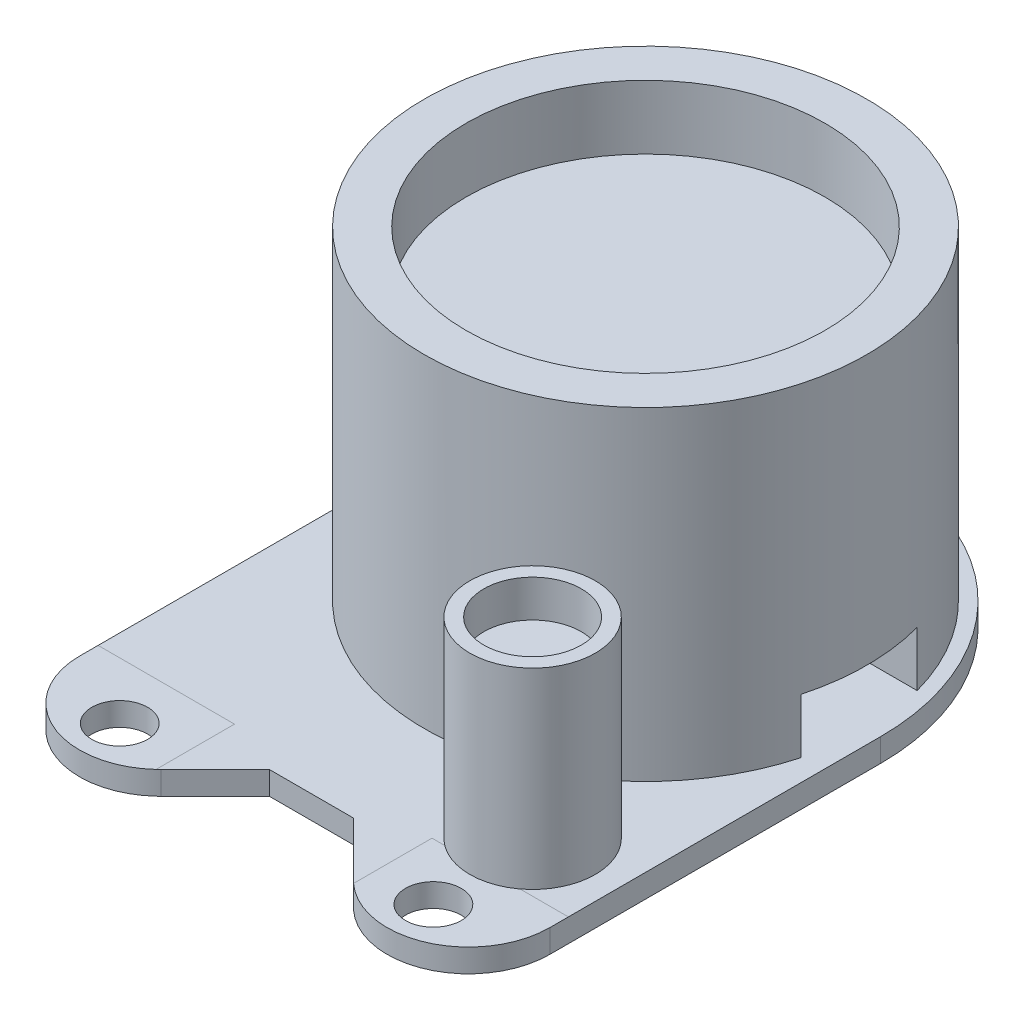
from build123d import *

# Parameters (mm, degrees)
SKETCH1_R               = 1.2
BOSS_EXTRUDE1_DEPTH     = 1
SKETCH4_R               = 9.525
SKETCH4_R_2             = 7.725
BOSS_EXTRUDE2_DEPTH     = 13.94
SKETCH5_W               = 5
SKETCH5_H               = 2.36
CUT_EXTRUDE1_DEPTH      = 11.12
CUT_EXTRUDE1_DEPTH_BACK = 11.12
BOSS_EXTRUDE3_START     = -2.75
SKETCH6_R               = 7.725
BOSS_EXTRUDE3_DEPTH     = 8.83
SKETCH7_R               = 2.7
SKETCH7_R_2             = 2.1
EXTRUDE_THIN1_DEPTH     = 8.25
BOSS_EXTRUDE4_START     = -1.6
SKETCH8_R               = 2.1
BOSS_EXTRUDE4_DEPTH     = 6.65
SKETCH9_R               = 4
CUT_EXTRUDE2_DEPTH      = 6.45
FILLET1_R               = 4
BOSS_EXTRUDE5_DEPTH     = 2.36


with BuildPart() as part:
    # Sketch1 → Boss-Extrude1 (new body)
    with BuildSketch(Plane(origin=(0, 0, 0), x_dir=(1, 0, 0), z_dir=(0, 1, 0))):
        with BuildLine():
            Line((-10.12, 0), (-10.12, -14.24))
            ThreePointArc((-10.12, -14.24), (-7.959392013, -17.473578364), (-4.145126266, -16.714873734))
            Line((-4.145126266, -16.714873734), (-1.810252532, -14.38))
            Line((-1.810252532, -14.38), (1.810252532, -14.38))
            Line((1.810252532, -14.38), (4.145126266, -16.714873734))
            ThreePointArc((4.145126266, -16.714873734), (7.959392013, -17.473578364), (10.12, -14.24))
            Line((10.12, -14.24), (10.12, 0))
            ThreePointArc((10.12, 0), (0, 10.12), (-10.12, 0))
        make_face()
        with Locations((-6.75, -15.88)):
            Circle(SKETCH1_R, mode=Mode.SUBTRACT)
        with Locations((6.75, -15.88)):
            Circle(SKETCH1_R, mode=Mode.SUBTRACT)
    extrude(amount=BOSS_EXTRUDE1_DEPTH)


with BuildPart() as body_2:
    # Sketch4 → Boss-Extrude2 (new body)
    with BuildSketch(Plane(origin=(0, 1, 0), x_dir=(1, 0, 0), z_dir=(0, 1, 0))):
        Circle(SKETCH4_R)
        Circle(SKETCH4_R_2, mode=Mode.SUBTRACT)
    extrude(amount=BOSS_EXTRUDE2_DEPTH)

    # Sketch5 → Cut-Extrude1 (cut, two sides)
    with BuildSketch(Plane(origin=(0, 0, 0), x_dir=(0, 0, -1), z_dir=(1, 0, 0))) as cut_extrude1_sk:
        with Locations((0, 2.18)):
            Rectangle(SKETCH5_W, SKETCH5_H)
    extrude(amount=CUT_EXTRUDE1_DEPTH, mode=Mode.SUBTRACT)
    extrude(cut_extrude1_sk.sketch, amount=-CUT_EXTRUDE1_DEPTH_BACK, mode=Mode.SUBTRACT)

    # Sketch10 → Boss-Extrude5 (add)
    with BuildSketch(Plane.XZ.offset(-1)):
        with BuildLine():
            Line((-7.309283481, -2.5), (-3.122498999, -2.5))
            ThreePointArc((-3.122498999, -2.5), (0, -4), (3.122498999, -2.5))
            Line((3.122498999, -2.5), (7.309283481, -2.5))
            ThreePointArc((7.309283481, -2.5), (0, -7.725), (-7.309283481, -2.5))
        make_face()
        with BuildLine():
            Line((-7.309283481, 2.5), (-3.122498999, 2.5))
            ThreePointArc((-3.122498999, 2.5), (0, 4), (3.122498999, 2.5))
            Line((3.122498999, 2.5), (7.309283481, 2.5))
            ThreePointArc((7.309283481, 2.5), (0, 7.725), (-7.309283481, 2.5))
        make_face()
    extrude(amount=-BOSS_EXTRUDE5_DEPTH)


with BuildPart() as body_3:
    # Sketch6 → Boss-Extrude3 (new body)
    with BuildSketch(Plane(origin=(0, 14.94, 0), x_dir=(1, 0, 0), z_dir=(0, 1, 0)).offset(BOSS_EXTRUDE3_START)):
        Circle(SKETCH6_R)
    extrude(amount=-BOSS_EXTRUDE3_DEPTH)

    # Sketch9 → Cut-Extrude2 (cut)
    with BuildSketch(Plane.XZ.offset(-1)):
        Circle(SKETCH9_R)
    extrude(amount=-CUT_EXTRUDE2_DEPTH, mode=Mode.SUBTRACT)

    # Fillet1
    fillet1_edges = [body_3.edges().sort_by_distance(p)[0] for p in [
        (-4, 7.45, 0),
    ]]
    fillet(fillet1_edges, radius=FILLET1_R)


with BuildPart() as body_4:
    # Sketch7 → Extrude-Thin1 (new body)
    with BuildSketch(Plane(origin=(0, 1, 0), x_dir=(1, 0, 0), z_dir=(0, 1, 0))):
        with Locations((6.42, -11.28)):
            Circle(SKETCH7_R)
        with Locations((6.42, -11.28)):
            Circle(SKETCH7_R_2, mode=Mode.SUBTRACT)
    extrude(amount=EXTRUDE_THIN1_DEPTH)

    # Sketch8 → Boss-Extrude4 (add)
    with BuildSketch(Plane(origin=(0, 9.25, 0), x_dir=(1, 0, 0), z_dir=(0, 1, 0)).offset(BOSS_EXTRUDE4_START)):
        with Locations((6.42, -11.28)):
            Circle(SKETCH8_R)
    extrude(amount=-BOSS_EXTRUDE4_DEPTH)


solid = Compound([part.part, body_2.part, body_3.part, body_4.part])
